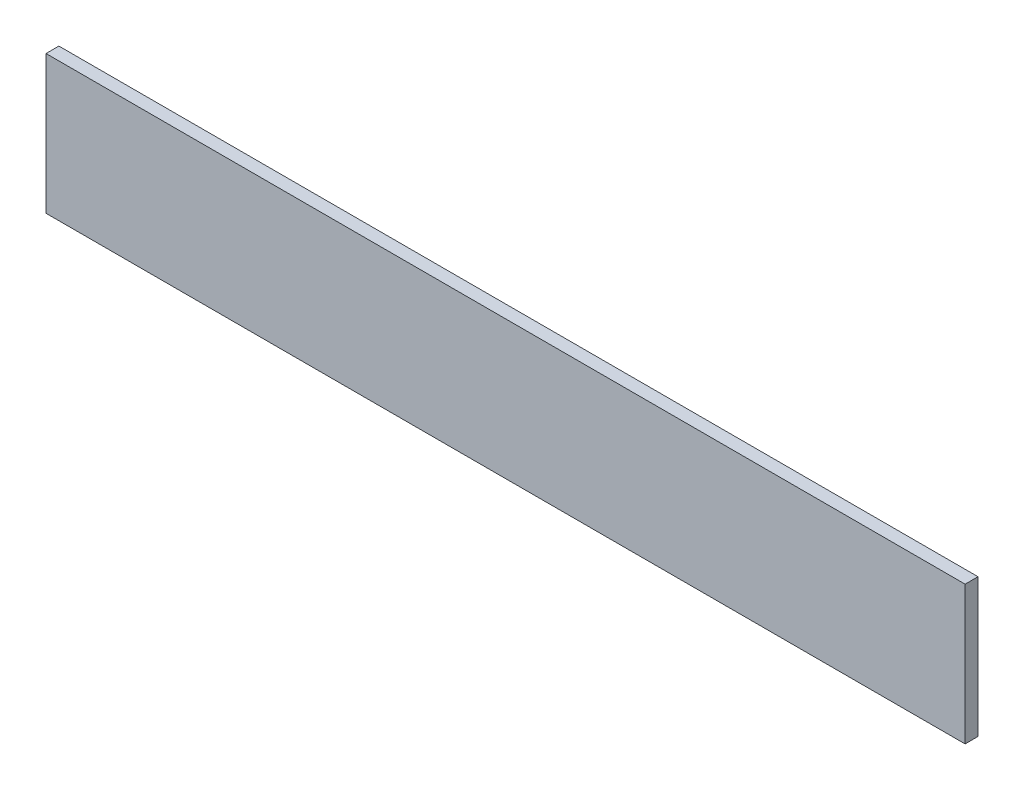
from build123d import *

# Parameters (mm, degrees)
ESQUISSE1_W        = 356.5
ESQUISSE1_H        = 53.68
BOSS_EXTRU_4_DEPTH = 5


with BuildPart() as part:
    # Esquisse1 → Boss.-Extru.4 (new body)
    with BuildSketch(Plane.XY):
        with Locations((-26.520642202, 99.719633028)):
            Rectangle(ESQUISSE1_W, ESQUISSE1_H)
    extrude(amount=BOSS_EXTRU_4_DEPTH)


solid = part.part
